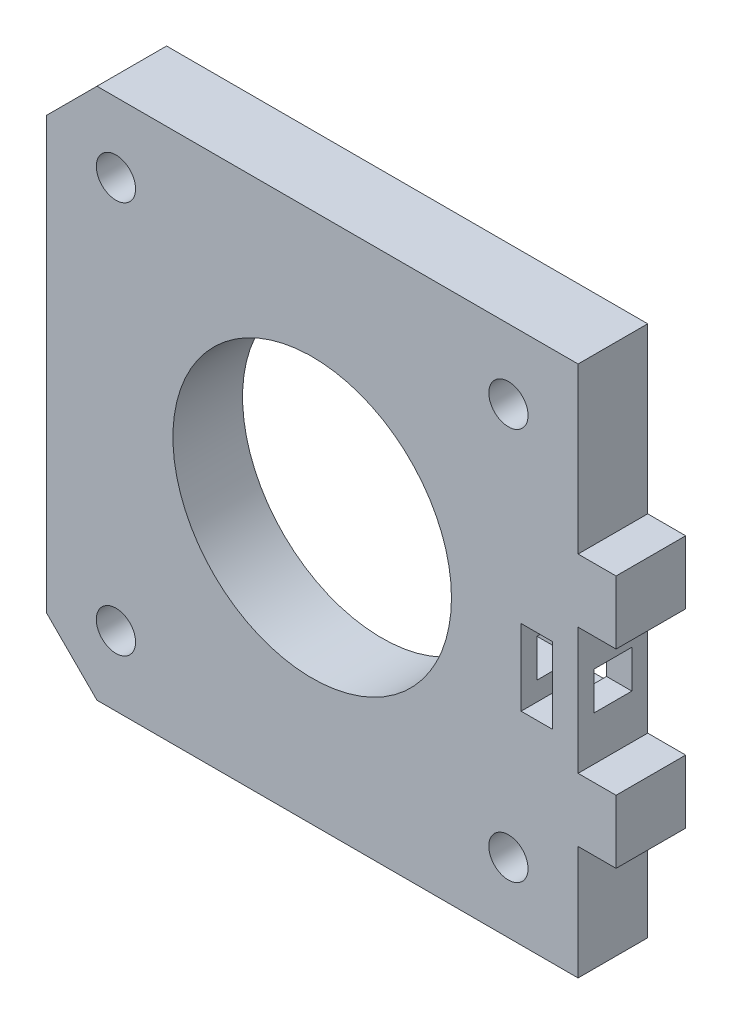
from build123d import *

# Parameters (mm, degrees)
CROQUIS1_R              = 11
CROQUIS1_R_2            = 1.55
SALIENTE_EXTRUIR1_DEPTH = 5.5
CROQUIS3_W              = 5.5
CROQUIS3_H              = 5
SALIENTE_EXTRUIR3_DEPTH = 3
CROQUIS6_W              = 3
CROQUIS6_H              = 3
CORTAR_EXTRUIR2_DEPTH   = 8
CROQUIS7_W              = 2.5
CROQUIS7_H              = 6
CORTAR_EXTRUIR3_DEPTH   = 6.5


with BuildPart() as part:
    # Croquis1 → Saliente-Extruir1 (new body)
    with BuildSketch(Plane.XY):
        Polygon((4, 0), (0, 4), (0, 38), (4, 42), (42, 42), (42, 0), align=None)
        with Locations((21, 21)):
            Circle(CROQUIS1_R, mode=Mode.SUBTRACT)
        with Locations((36.5, 36.5)):
            Circle(CROQUIS1_R_2, mode=Mode.SUBTRACT)
        with Locations((36.5, 5.5)):
            Circle(CROQUIS1_R_2, mode=Mode.SUBTRACT)
        with Locations((5.5, 5.5)):
            Circle(CROQUIS1_R_2, mode=Mode.SUBTRACT)
        with Locations((5.5, 36.5)):
            Circle(CROQUIS1_R_2, mode=Mode.SUBTRACT)
    extrude(amount=SALIENTE_EXTRUIR1_DEPTH)

    # Croquis3 → Saliente-Extruir3 (add)
    with BuildSketch(Plane(origin=(42, 0, 0), x_dir=(0, 0, -1), z_dir=(1, 0, 0))):
        with Locations((-2.75, 26.5)):
            Rectangle(CROQUIS3_W, CROQUIS3_H)
        with Locations((-2.75, 11.5)):
            Rectangle(CROQUIS3_W, CROQUIS3_H)
    extrude(amount=SALIENTE_EXTRUIR3_DEPTH)

    # Croquis6 → Cortar-Extruir2 (cut)
    with BuildSketch(Plane(origin=(42, 0, 0), x_dir=(0, 0, -1), z_dir=(1, 0, 0))):
        with Locations((-2.75, 19)):
            Rectangle(CROQUIS6_W, CROQUIS6_H)
    extrude(amount=-CORTAR_EXTRUIR2_DEPTH, mode=Mode.SUBTRACT)

    # Croquis7 → Cortar-Extruir3 (cut, through all)
    with BuildSketch(Plane.XY.offset(5.5)):
        with Locations((38.75, 19)):
            Rectangle(CROQUIS7_W, CROQUIS7_H)
    extrude(amount=-CORTAR_EXTRUIR3_DEPTH, mode=Mode.SUBTRACT)


solid = part.part
